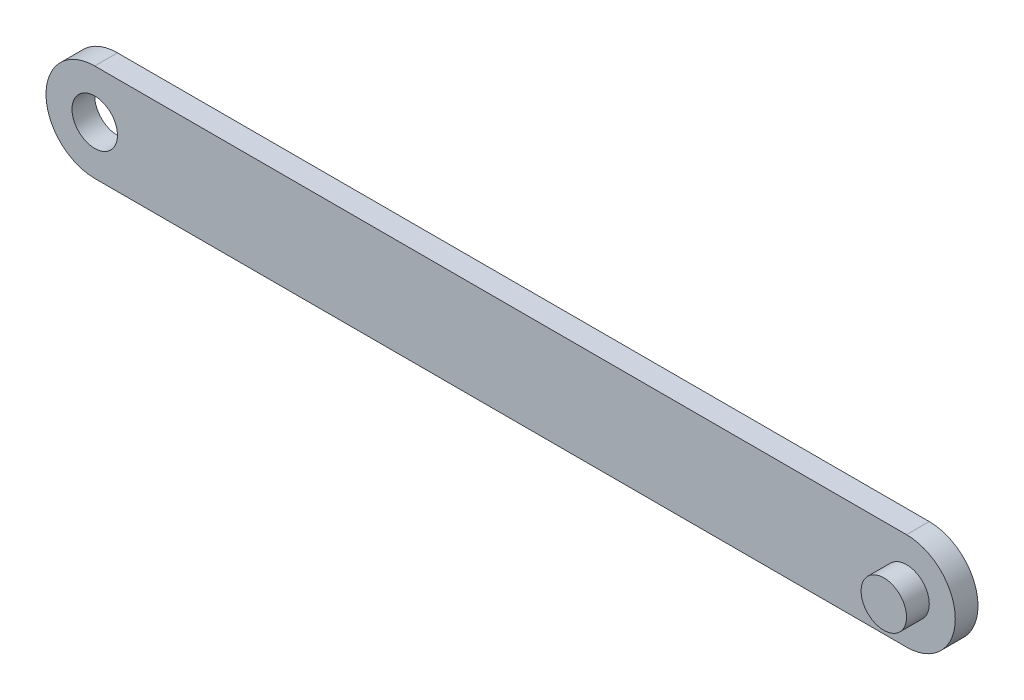
from build123d import *

# Parameters (mm, degrees)
BOSS_EXTRUDE1_DEPTH = 7
SKETCH2_R           = 7
BOSS_EXTRUDE2_DEPTH = 7
SKETCH3_R           = 7
CUT_EXTRUDE1_DEPTH  = 7


with BuildPart() as part:
    # Sketch1 → Boss-Extrude1 (new body)
    with BuildSketch(Plane.XY):
        with BuildLine():
            Line((-125, 15), (125, 15))
            ThreePointArc((125, 15), (140, 0), (125, -15))
            Line((125, -15), (-125, -15))
            ThreePointArc((-125, -15), (-140, 0), (-125, 15))
        make_face()
    extrude(amount=BOSS_EXTRUDE1_DEPTH)

    # Sketch2 → Boss-Extrude2 (add)
    with BuildSketch(Plane.XY.offset(7)):
        with Locations((125, 0)):
            Circle(SKETCH2_R)
    extrude(amount=BOSS_EXTRUDE2_DEPTH)

    # Sketch3 → Cut-Extrude1 (cut)
    with BuildSketch(Plane.XY.offset(7)):
        with Locations((-125, 0)):
            Circle(SKETCH3_R)
    extrude(amount=-CUT_EXTRUDE1_DEPTH, mode=Mode.SUBTRACT)


solid = part.part
